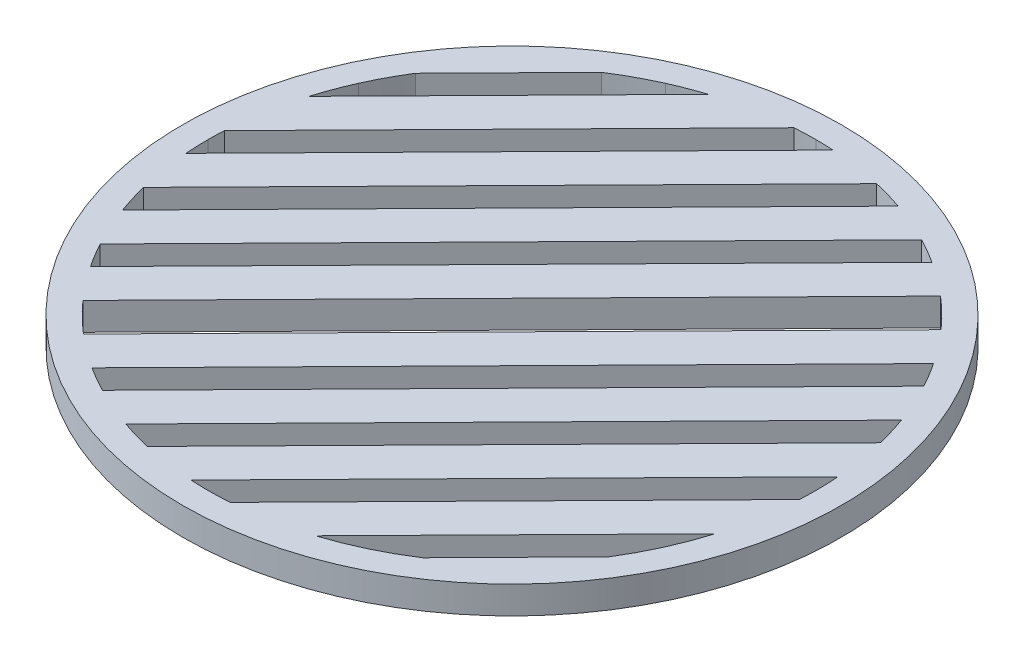
from build123d import *

# Parameters (mm, degrees)
SKETCH1_R           = 30.315
SKETCH1_R_2         = 27.955876632
BOSS_EXTRUDE1_DEPTH = 2.54
BOSS_EXTRUDE3_DEPTH = 2.54


with BuildPart() as part:
    # Sketch1 → Boss-Extrude1 (new body)
    with BuildSketch(Plane(origin=(0, 0, 0), x_dir=(1, 0, 0), z_dir=(0, 1, 0))):
        Circle(SKETCH1_R)
        Circle(SKETCH1_R_2, mode=Mode.SUBTRACT)
    extrude(amount=BOSS_EXTRUDE1_DEPTH)

    # Sketch2 → Boss-Extrude3 (add)
    with BuildSketch(Plane(origin=(0, 2.54, 0), x_dir=(1, 0, 0), z_dir=(0, 1, 0))):
        with BuildLine():
            ThreePointArc((23.249475333, 15.523947146), (22.126610026, 17.086373723), (20.89893406, 18.567864536))
            Line((20.89893406, 18.567864536), (-18.197502423, -21.222204028))
            ThreePointArc((-18.197502423, -21.222204028), (-16.694652957, -22.423639332), (-15.112723253, -23.51885699))
            Line((-15.112723253, -23.51885699), (23.249475333, 15.523947146))
        make_face()
        with BuildLine():
            ThreePointArc((26.276234192, 9.544137201), (25.507547042, 11.440982568), (24.602142837, 13.276505792))
            Line((24.602142837, 13.276505792), (-12.841843795, -24.831795871))
            ThreePointArc((-12.841843795, -24.831795871), (-10.990683551, -25.70478386), (-9.080614707, -26.439997632))
            Line((-9.080614707, -26.439997632), (26.276234192, 9.544137201))
        make_face()
        with BuildLine():
            ThreePointArc((27.875984112, 2.112000943), (27.597491722, 4.462005025), (27.121248921, 6.780036517))
            Line((27.121248921, 6.780036517), (-6.302082474, -27.236277181))
            ThreePointArc((-6.302082474, -27.236277181), (-3.97603503, -27.671685595), (-1.621497222, -27.908811959))
            Line((-1.621497222, -27.908811959), (27.875984112, 2.112000943))
        make_face()
        with BuildLine():
            ThreePointArc((26.762200244, -8.081811449), (27.538835575, -4.810776795), (27.917192699, -1.470166667))
            Line((27.917192699, -1.470166667), (1.960841153, -27.887024584))
            ThreePointArc((1.960841153, -27.887024584), (5.294281665, -27.449983968), (8.551154051, -26.615950154))
            Line((8.551154051, -26.615950154), (26.762200244, -8.081811449))
        make_face()
        with BuildLine():
            ThreePointArc((15.229009426, -23.443726455), (19.940833039, -19.593218621), (23.707891831, -14.814415383))
            Line((23.707891831, -14.814415383), (15.229009426, -23.443726455))
        make_face()
        with BuildLine():
            ThreePointArc((16.305164724, 22.708426665), (15.714169419, 23.121330362), (15.112723252, 23.518856991))
            Line((15.112723252, 23.518856991), (-23.249475334, -15.523947145))
            ThreePointArc((-23.249475334, -15.523947145), (-22.982270651, -15.916855029), (-22.708426665, -16.305164724))
            ThreePointArc((-22.708426665, -16.305164724), (-22.41820217, -16.701953471), (-22.121045331, -17.0935775))
            ThreePointArc((-22.121045331, -17.0935775), (-21.522616878, -17.841188329), (-20.898934061, -18.567864535))
            Line((-20.898934061, -18.567864535), (18.197502422, 21.222204029))
            ThreePointArc((18.197502422, 21.222204029), (17.651262262, 21.678652606), (17.0935775, 22.121045331))
            ThreePointArc((17.0935775, 22.121045331), (16.701953471, 22.41820217), (16.305164724, 22.708426665))
        make_face()
        with BuildLine():
            ThreePointArc((12.841843795, 24.831795872), (10.99068355, 25.704783861), (9.080614706, 26.439997633))
            Line((9.080614706, 26.439997633), (-26.276234193, -9.544137201))
            ThreePointArc((-26.276234193, -9.544137201), (-25.507547043, -11.440982567), (-24.602142838, -13.276505791))
            Line((-24.602142838, -13.276505791), (12.841843795, 24.831795872))
        make_face()
        with BuildLine():
            ThreePointArc((3.386258142, 27.750032325), (2.505135962, 27.843407336), (1.621497221, 27.90881196))
            Line((1.621497221, 27.90881196), (-27.875984113, -2.112000942))
            ThreePointArc((-27.875984113, -2.112000942), (-27.820304798, -2.74985076), (-27.750032325, -3.386258142))
            ThreePointArc((-27.750032325, -3.386258142), (-27.488066672, -5.092860582), (-27.121248922, -6.780036516))
            Line((-27.121248922, -6.780036516), (6.302082473, 27.236277182))
            ThreePointArc((6.302082473, 27.236277182), (4.850976402, 27.531782837), (3.386258142, 27.750032325))
        make_face()
        with BuildLine():
            Line((-27.9171927, 1.470166667), (-1.960841154, 27.887024585))
            ThreePointArc((-1.960841154, 27.887024585), (-5.294281666, 27.449983969), (-8.551154052, 26.615950155))
            Line((-8.551154052, 26.615950155), (-26.762200245, 8.08181145))
            ThreePointArc((-26.762200245, 8.08181145), (-27.538835576, 4.810776796), (-27.9171927, 1.470166667))
        make_face()
        with BuildLine():
            Line((-23.707891832, 14.814415383), (-15.229009427, 23.443726455))
            ThreePointArc((-15.229009427, 23.443726455), (-19.940833039, 19.593218621), (-23.707891832, 14.814415383))
        make_face()
    extrude(amount=-BOSS_EXTRUDE3_DEPTH)


solid = part.part
